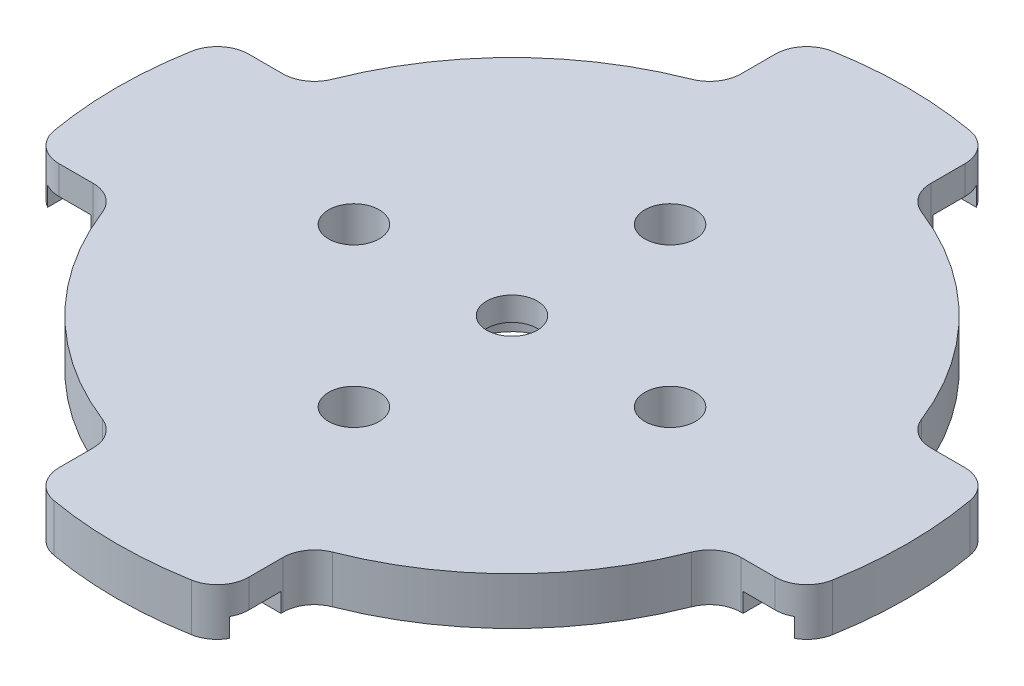
from build123d import *

# Parameters (mm, degrees)
SKIZZE1_R                       = 19
SKIZZE1_R_2                     = 1.6
AUFSATZ_LINEAR_AUSTRAGEN1_DEPTH = 3
SKIZZE6_R                       = 3
SCHNITT_LINEAR_AUSTRAGEN2_DEPTH = 1.5
SKIZZE7_W                       = 3
SKIZZE7_H                       = 12
SKIZZE7_W_2                     = 12
SKIZZE7_H_2                     = 3
SCHNITT_LINEAR_AUSTRAGEN3_DEPTH = 1.2


with BuildPart() as part:
    # Skizze1 → Aufsatz-Linear austragen1 (new body)
    with BuildSketch(Plane(origin=(0, 0, 0), x_dir=(1, 0, 0), z_dir=(0, 1, 0))):
        with BuildLine():
            ThreePointArc((6, -20.493901532), (6.348554352, -19.365749382), (7.272727273, -18.630819574))
            ThreePointArc((7.272727273, -18.630819574), (14.142135624, -14.142135624), (18.630819574, -7.272727273))
            ThreePointArc((18.630819574, -7.272727273), (19.365749382, -6.348554352), (20.493901532, -6))
            Line((20.493901532, -6), (22.649503306, -6))
            ThreePointArc((22.649503306, -6), (23.93487248, -5.532261755), (24.619025332, -4.347826087))
            ThreePointArc((24.619025332, -4.347826087), (25, 0), (24.619025332, 4.347826087))
            ThreePointArc((24.619025332, 4.347826087), (23.93487248, 5.532261755), (22.649503306, 6))
            Line((22.649503306, 6), (20.493901532, 6))
            ThreePointArc((20.493901532, 6), (19.365749382, 6.348554352), (18.630819574, 7.272727273))
            ThreePointArc((18.630819574, 7.272727273), (14.142135624, 14.142135624), (7.272727273, 18.630819574))
            ThreePointArc((7.272727273, 18.630819574), (6.348554352, 19.365749382), (6, 20.493901532))
            Line((6, 20.493901532), (6, 22.649503306))
            ThreePointArc((6, 22.649503306), (5.532261755, 23.93487248), (4.347826087, 24.619025332))
            ThreePointArc((4.347826087, 24.619025332), (0, 25), (-4.347826087, 24.619025332))
            ThreePointArc((-4.347826087, 24.619025332), (-5.532261755, 23.93487248), (-6, 22.649503306))
            Line((-6, 22.649503306), (-6, 20.493901532))
            ThreePointArc((-6, 20.493901532), (-6.348554352, 19.365749382), (-7.272727273, 18.630819574))
            ThreePointArc((-7.272727273, 18.630819574), (-14.142135624, 14.142135624), (-18.630819574, 7.272727273))
            ThreePointArc((-18.630819574, 7.272727273), (-19.365749382, 6.348554352), (-20.493901532, 6))
            Line((-20.493901532, 6), (-22.649503306, 6))
            ThreePointArc((-22.649503306, 6), (-23.93487248, 5.532261755), (-24.619025332, 4.347826087))
            ThreePointArc((-24.619025332, 4.347826087), (-25, 0), (-24.619025332, -4.347826087))
            ThreePointArc((-24.619025332, -4.347826087), (-23.93487248, -5.532261755), (-22.649503306, -6))
            Line((-22.649503306, -6), (-20.493901532, -6))
            ThreePointArc((-20.493901532, -6), (-19.365749382, -6.348554352), (-18.630819574, -7.272727273))
            ThreePointArc((-18.630819574, -7.272727273), (-14.142135624, -14.142135624), (-7.272727273, -18.630819574))
            ThreePointArc((-7.272727273, -18.630819574), (-6.348554352, -19.365749382), (-6, -20.493901532))
            Line((-6, -20.493901532), (-6, -22.649503306))
            ThreePointArc((-6, -22.649503306), (-5.532261755, -23.93487248), (-4.347826087, -24.619025332))
            ThreePointArc((-4.347826087, -24.619025332), (0, -25), (4.347826087, -24.619025332))
            ThreePointArc((4.347826087, -24.619025332), (5.532261755, -23.93487248), (6, -22.649503306))
            Line((6, -22.649503306), (6, -20.493901532))
        make_face()
        Circle(SKIZZE1_R, mode=Mode.SUBTRACT)
        Circle(SKIZZE1_R)
        with Locations(Location((0, -10, 0), (0, 0, 270))):
            Circle(SKIZZE1_R_2, mode=Mode.SUBTRACT)
        with Locations(Location((-10, 0, 0), (0, 0, 270))):
            Circle(SKIZZE1_R_2, mode=Mode.SUBTRACT)
        with Locations(Location((10, 0, 0), (0, 0, 270))):
            Circle(SKIZZE1_R_2, mode=Mode.SUBTRACT)
        with Locations(Location((0, 10, 0), (0, 0, 270))):
            Circle(SKIZZE1_R_2, mode=Mode.SUBTRACT)
        with Locations(Location((0, 0, 0), (0, 0, 270))):
            Circle(SKIZZE1_R_2, mode=Mode.SUBTRACT)
    extrude(amount=AUFSATZ_LINEAR_AUSTRAGEN1_DEPTH)

    # Skizze6 → Schnitt-Linear austragen2 (cut)
    with BuildSketch(Plane.XZ):
        with Locations(Location((0, 0, 0), (0, 0, 270))):
            Circle(SKIZZE6_R)
    extrude(amount=-SCHNITT_LINEAR_AUSTRAGEN2_DEPTH, mode=Mode.SUBTRACT)

    # Skizze7 → Schnitt-Linear austragen3 (cut)
    with BuildSketch(Plane.XZ):
        with Locations((-22.119025332, 0)):
            Rectangle(SKIZZE7_W, SKIZZE7_H)
        with Locations((0, 22.119025332)):
            Rectangle(SKIZZE7_W_2, SKIZZE7_H_2)
        with Locations((22.119025332, 0)):
            Rectangle(SKIZZE7_W, SKIZZE7_H)
        with Locations((0, -22.119025332)):
            Rectangle(SKIZZE7_W_2, SKIZZE7_H_2)
    extrude(amount=-SCHNITT_LINEAR_AUSTRAGEN3_DEPTH, mode=Mode.SUBTRACT)


solid = part.part
